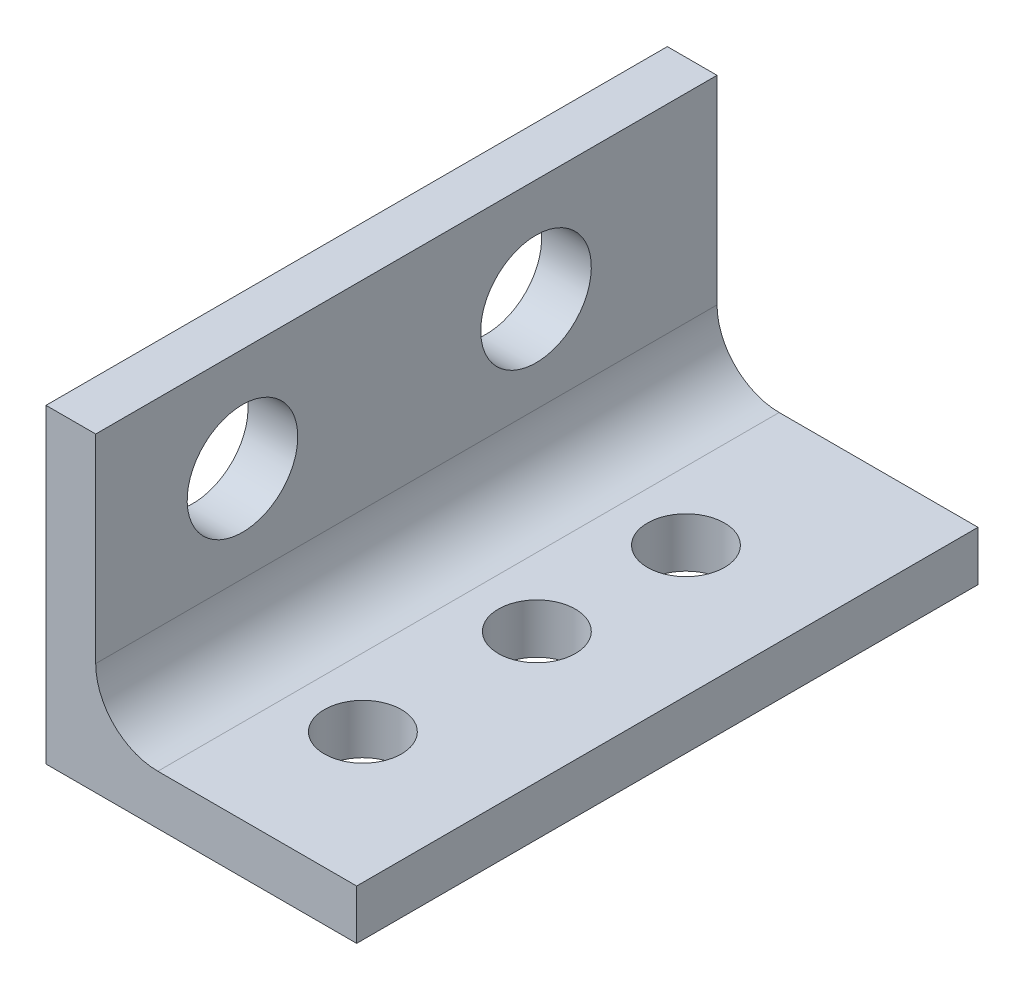
from build123d import *

# Parameters (mm, degrees)
BOSS_EXTRUDE1_DEPTH = 12.7
SKETCH3_R           = 0.7874
CUT_EXTRUDE1_DEPTH  = 2.54
FILLET1_R           = 1.27
CUT_EXTRUDE2_REACH  = 3.016
SKETCH4_R           = 1.1303


with BuildPart() as part:
    # Sketch1 → Boss-Extrude1 (new body)
    with BuildSketch(Plane.XY):
        Polygon((-6.35, 6.35), (-6.35, 0), (0, 0), (0, 1.016), (-5.334, 1.016), (-5.334, 6.35), align=None)
    extrude(amount=BOSS_EXTRUDE1_DEPTH)

    # Sketch3 → Cut-Extrude1 (cut)
    with BuildSketch(Plane(origin=(0, 1.016, 0), x_dir=(1, 0, 0), z_dir=(0, 1, 0))):
        with Locations((-2.667, -9.906)):
            Circle(SKETCH3_R)
        with Locations((-2.667, -6.35)):
            Circle(SKETCH3_R)
        with Locations((-2.667, -3.302)):
            Circle(SKETCH3_R)
    extrude(amount=-CUT_EXTRUDE1_DEPTH, mode=Mode.SUBTRACT)

    # Fillet1
    fillet1_edges = [part.edges().sort_by_distance(p)[0] for p in [
        (-5.334, 1.016, 6.35),
    ]]
    fillet(fillet1_edges, radius=FILLET1_R)

    # Sketch4 → Cut-Extrude2 (cut, up to next)
    with BuildSketch(Plane(origin=(-5.334, 0, 0), x_dir=(0, 0, -1), z_dir=(1, 0, 0)), mode=Mode.PRIVATE) as cut_extrude2_sk1:
        with Locations((-9.7, 4.24)):
            Circle(SKETCH4_R)
    cut_extrude2_tool1 = extrude(cut_extrude2_sk1.sketch, amount=-CUT_EXTRUDE2_REACH, mode=Mode.PRIVATE) & part.part
    add(cut_extrude2_tool1.solids().sort_by_distance((-5.334, 4.24, 9.7))[0], mode=Mode.SUBTRACT)
    # Sketch4 → Cut-Extrude2 (cut, up to next)
    with BuildSketch(Plane(origin=(-5.334, 0, 0), x_dir=(0, 0, -1), z_dir=(1, 0, 0)), mode=Mode.PRIVATE) as cut_extrude2_sk2:
        with Locations((-3.7, 4.24)):
            Circle(SKETCH4_R)
    cut_extrude2_tool2 = extrude(cut_extrude2_sk2.sketch, amount=-CUT_EXTRUDE2_REACH, mode=Mode.PRIVATE) & part.part
    add(cut_extrude2_tool2.solids().sort_by_distance((-5.334, 4.24, 3.7))[0], mode=Mode.SUBTRACT)


solid = part.part
